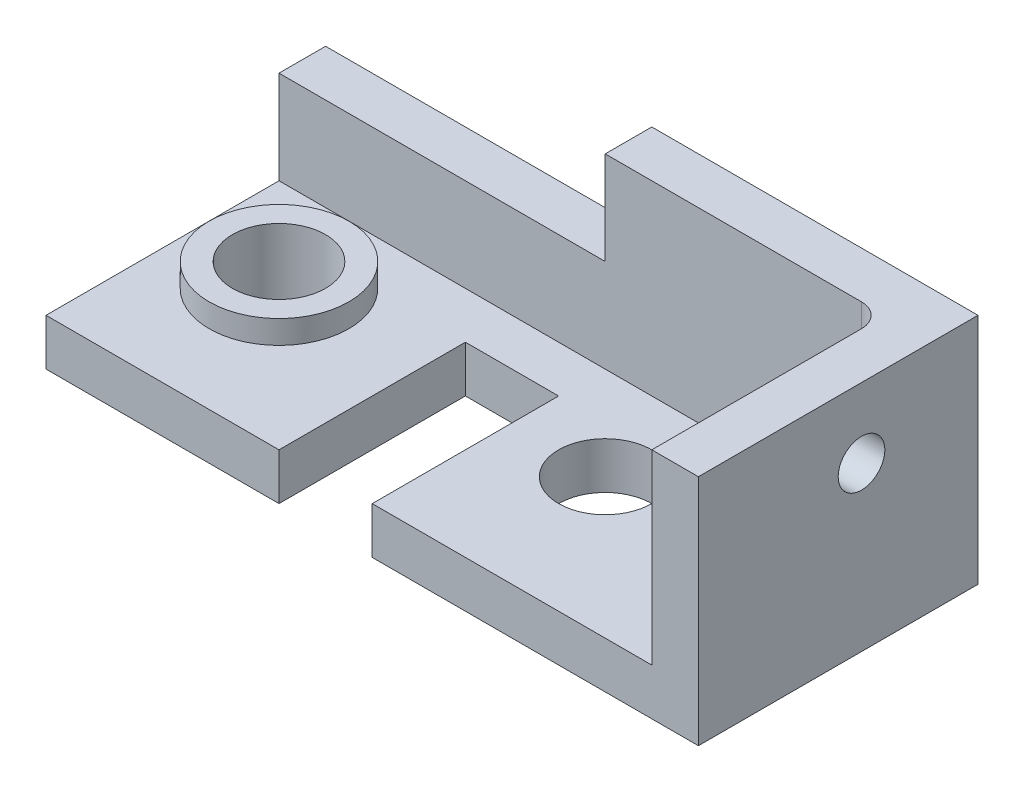
from build123d import *

# Parameters (mm, degrees)
IZIM1_W                     = 140
IZIM1_H                     = 50
Y_KSEKLIK_EKSTR_ZYON1_DEPTH = 60
IZIM2_W                     = 130
IZIM2_H                     = 50
KES_EKSTR_ZYON1_DEPTH       = 40
RADYUS1_R                   = 5
IZIM3_R                     = 15
IZIM3_R_2                   = 10
Y_KSEKLIK_EKSTR_ZYON2_DEPTH = 5
IZIM3_2_R                   = 10
KES_EKSTR_ZYON2_DEPTH       = 158.48015748
IZIM5_W                     = 70
IZIM5_H                     = 20
KES_EKSTR_ZYON3_DEPTH       = 157.843871414
IZIM6_W                     = 20
IZIM6_H                     = 40
KES_EKSTR_ZYON5_DEPTH       = 158.48015748
IZIM7_R                     = 10
KES_EKSTR_ZYON6_DEPTH       = 158.48015748
IZIM8_R                     = 5
KES_EKSTR_ZYON7_DEPTH       = 152.657508881


with BuildPart() as part:
    # Çizim1 → Yükseklik-Ekstrüzyon1 (new body)
    with BuildSketch(Plane.XY):
        with Locations((70, 25)):
            Rectangle(IZIM1_W, IZIM1_H)
    extrude(amount=Y_KSEKLIK_EKSTR_ZYON1_DEPTH)

    # Çizim2 → Kes-Ekstrüzyon1 (cut)
    with BuildSketch(Plane(origin=(0, 50, 0), x_dir=(1, 0, 0), z_dir=(0, 1, 0))):
        with Locations((65, -35)):
            Rectangle(IZIM2_W, IZIM2_H)
    extrude(amount=-KES_EKSTR_ZYON1_DEPTH, mode=Mode.SUBTRACT)

    # Radyus1
    radyus1_edges = [part.edges().sort_by_distance(p)[0] for p in [
        (130, 30, 10),
    ]]
    fillet(radyus1_edges, radius=RADYUS1_R)

    # Çizim3 → Yükseklik-Ekstrüzyon2 (add)
    with BuildSketch(Plane(origin=(0, 10, 0), x_dir=(1, 0, 0), z_dir=(0, 1, 0))):
        with Locations((20, -30)):
            Circle(IZIM3_R)
        with Locations((20, -30)):
            Circle(IZIM3_R_2, mode=Mode.SUBTRACT)
    extrude(amount=Y_KSEKLIK_EKSTR_ZYON2_DEPTH)

    # Çizim3<2> → Kes-Ekstrüzyon2 (cut, through all)
    with BuildSketch(Plane(origin=(0, 10, 0), x_dir=(1, 0, 0), z_dir=(0, 1, 0))):
        with Locations((20, -30)):
            Circle(IZIM3_2_R)
    extrude(amount=-KES_EKSTR_ZYON2_DEPTH, mode=Mode.SUBTRACT)

    # Çizim5 → Kes-Ekstrüzyon3 (cut, through all)
    with BuildSketch(Plane.XY.offset(10)):
        with Locations((35, 40)):
            Rectangle(IZIM5_W, IZIM5_H)
    extrude(amount=-KES_EKSTR_ZYON3_DEPTH, mode=Mode.SUBTRACT)

    # Çizim6 → Kes-Ekstrüzyon5 (cut, through all)
    with BuildSketch(Plane(origin=(0, 10, 0), x_dir=(1, 0, 0), z_dir=(0, 1, 0))):
        with Locations((60, -40)):
            Rectangle(IZIM6_W, IZIM6_H)
    extrude(amount=-KES_EKSTR_ZYON5_DEPTH, mode=Mode.SUBTRACT)

    # Çizim7 → Kes-Ekstrüzyon6 (cut, through all)
    with BuildSketch(Plane(origin=(0, 10, 0), x_dir=(1, 0, 0), z_dir=(0, 1, 0))):
        with Locations((90, -30)):
            Circle(IZIM7_R)
    extrude(amount=-KES_EKSTR_ZYON6_DEPTH, mode=Mode.SUBTRACT)

    # Çizim8 → Kes-Ekstrüzyon7 (cut, through all)
    with BuildSketch(Plane.ZY.offset(-130)):
        with Locations((25, 35)):
            Circle(IZIM8_R)
    extrude(amount=-KES_EKSTR_ZYON7_DEPTH, mode=Mode.SUBTRACT)


solid = part.part
